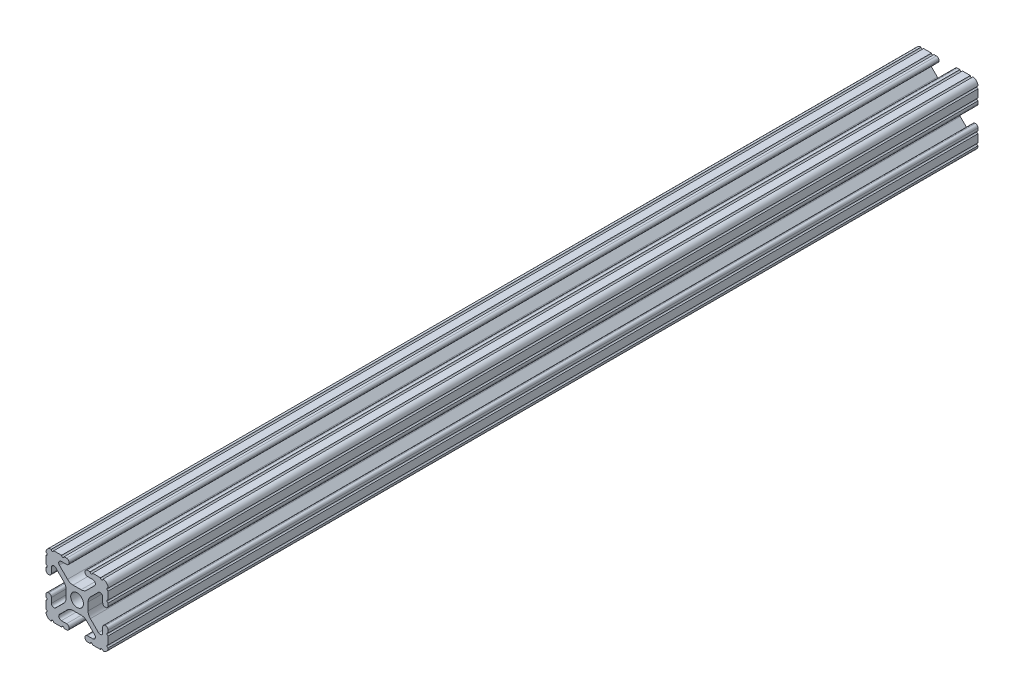
from build123d import *

# Parameters (mm, degrees)
SKETCH1_R           = 2.6035
BOSS_EXTRUDE1_DEPTH = 177.8


with BuildPart() as part:
    # Sketch1 → Boss-Extrude1 (new body, symmetric)
    with BuildSketch(Plane.XY):
        with BuildLine():
            Line((-7.179650497, -8.645192506), (-3.952270251, -5.423690499))
            ThreePointArc((-3.952270251, -5.423690499), (-2.922936451, -4.736929036), (-1.709253557, -4.4958))
            Line((-1.709253557, -4.4958), (1.709253557, -4.4958))
            ThreePointArc((1.709253557, -4.4958), (2.922936451, -4.736929036), (3.952270251, -5.423690499))
            Line((3.952270251, -5.423690499), (7.179650497, -8.645192506))
            ThreePointArc((7.179650497, -8.645192506), (7.41473083, -9.822813117), (6.416408329, -10.4902))
            Line((6.416408329, -10.4902), (4.287512407, -10.4902))
            ThreePointArc((4.287512407, -10.4902), (3.54574862, -10.79744862), (3.2385, -11.539212407))
            Line((3.2385, -11.539212407), (3.2385, -11.650987593))
            ThreePointArc((3.2385, -11.650987593), (3.54574862, -12.39275138), (4.287512407, -12.7))
            Line((4.287512407, -12.7), (5.317126718, -12.7))
            ThreePointArc((5.317126718, -12.7), (5.825126718, -12.192), (6.333126718, -12.7))
            Line((6.333126718, -12.7), (9.550443118, -12.7))
            ThreePointArc((9.550443118, -12.7), (10.058366869, -12.192000006), (10.566443095, -12.699847501))
            ThreePointArc((10.566443095, -12.699847501), (12.082537762, -12.08250727), (12.699846982, -10.566399977))
            ThreePointArc((12.699846982, -10.566399977), (12.192000006, -10.058323491), (12.7, -9.5504))
            Line((12.7, -9.5504), (12.7, -6.3330836))
            ThreePointArc((12.7, -6.3330836), (12.192, -5.8250836), (12.7, -5.3170836))
            Line((12.7, -5.3170836), (12.7, -4.287469289))
            ThreePointArc((12.7, -4.287469289), (12.39275138, -3.545705502), (11.650987593, -3.238456882))
            Line((11.650987593, -3.238456882), (11.539212407, -3.238456882))
            ThreePointArc((11.539212407, -3.238456882), (10.79744862, -3.545705502), (10.4902, -4.287469289))
            Line((10.4902, -4.287469289), (10.4902, -6.402089023))
            ThreePointArc((10.4902, -6.402089023), (9.856505071, -7.351067942), (8.737131347, -7.129408934))
            Line((8.737131347, -7.129408934), (5.441005833, -3.840816462))
            ThreePointArc((5.441005833, -3.840816462), (4.750877967, -2.809883091), (4.5085, -1.593185507))
            Line((4.5085, -1.593185507), (4.5085, 1.593185507))
            ThreePointArc((4.5085, 1.593185507), (4.750877967, 2.809883091), (5.441005833, 3.840816462))
            Line((5.441005833, 3.840816462), (8.737131347, 7.129408934))
            ThreePointArc((8.737131347, 7.129408934), (9.856505071, 7.351067942), (10.4902, 6.402089023))
            Line((10.4902, 6.402089023), (10.4902, 4.287469289))
            ThreePointArc((10.4902, 4.287469289), (10.79744862, 3.545705502), (11.539212407, 3.238456882))
            Line((11.539212407, 3.238456882), (11.650987593, 3.238456882))
            ThreePointArc((11.650987593, 3.238456882), (12.39275138, 3.545705502), (12.7, 4.287469289))
            Line((12.7, 4.287469289), (12.7, 5.3170836))
            ThreePointArc((12.7, 5.3170836), (12.192, 5.8250836), (12.7, 6.3330836))
            Line((12.7, 6.3330836), (12.7, 9.5504))
            ThreePointArc((12.7, 9.5504), (12.192000006, 10.058323491), (12.699846982, 10.566399977))
            ThreePointArc((12.699846982, 10.566399977), (12.082537762, 12.08250727), (10.566443095, 12.699847501))
            ThreePointArc((10.566443095, 12.699847501), (10.058366869, 12.192000006), (9.550443118, 12.7))
            Line((9.550443118, 12.7), (6.333126718, 12.7))
            ThreePointArc((6.333126718, 12.7), (5.825126718, 12.192), (5.317126718, 12.7))
            Line((5.317126718, 12.7), (4.287512407, 12.7))
            ThreePointArc((4.287512407, 12.7), (3.54574862, 12.39275138), (3.2385, 11.650987593))
            Line((3.2385, 11.650987593), (3.2385, 11.539212407))
            ThreePointArc((3.2385, 11.539212407), (3.54574862, 10.79744862), (4.287512407, 10.4902))
            Line((4.287512407, 10.4902), (6.476788598, 10.4902))
            ThreePointArc((6.476788598, 10.4902), (7.432222385, 9.85140422), (7.207036008, 8.724370562))
            Line((7.207036008, 8.724370562), (3.898272566, 5.423169045))
            ThreePointArc((3.898272566, 5.423169045), (2.869120213, 4.736787962), (1.655778399, 4.4958))
            Line((1.655778399, 4.4958), (-1.655778399, 4.4958))
            ThreePointArc((-1.655778399, 4.4958), (-2.869120213, 4.736787962), (-3.898272566, 5.423169045))
            Line((-3.898272566, 5.423169045), (-7.207036008, 8.724370562))
            ThreePointArc((-7.207036008, 8.724370562), (-7.432222385, 9.85140422), (-6.476788598, 10.4902))
            Line((-6.476788598, 10.4902), (-4.287512407, 10.4902))
            ThreePointArc((-4.287512407, 10.4902), (-3.54574862, 10.79744862), (-3.2385, 11.539212407))
            Line((-3.2385, 11.539212407), (-3.2385, 11.650987593))
            ThreePointArc((-3.2385, 11.650987593), (-3.54574862, 12.39275138), (-4.287512407, 12.7))
            Line((-4.287512407, 12.7), (-5.317126718, 12.7))
            ThreePointArc((-5.317126718, 12.7), (-5.825126718, 12.192), (-6.333126718, 12.7))
            Line((-6.333126718, 12.7), (-9.550443118, 12.7))
            ThreePointArc((-9.550443118, 12.7), (-10.058366869, 12.192000006), (-10.566443095, 12.699847501))
            ThreePointArc((-10.566443095, 12.699847501), (-12.082537762, 12.08250727), (-12.699846982, 10.566399977))
            ThreePointArc((-12.699846982, 10.566399977), (-12.192000006, 10.058323491), (-12.7, 9.5504))
            Line((-12.7, 9.5504), (-12.7, 6.3330836))
            ThreePointArc((-12.7, 6.3330836), (-12.192, 5.8250836), (-12.7, 5.3170836))
            Line((-12.7, 5.3170836), (-12.7, 4.287469289))
            ThreePointArc((-12.7, 4.287469289), (-12.39275138, 3.545705502), (-11.650987593, 3.238456882))
            Line((-11.650987593, 3.238456882), (-11.539212407, 3.238456882))
            ThreePointArc((-11.539212407, 3.238456882), (-10.79744862, 3.545705502), (-10.4902, 4.287469289))
            Line((-10.4902, 4.287469289), (-10.4902, 6.402089023))
            ThreePointArc((-10.4902, 6.402089023), (-9.856505071, 7.351067942), (-8.737131347, 7.129408934))
            Line((-8.737131347, 7.129408934), (-5.441005833, 3.840816462))
            ThreePointArc((-5.441005833, 3.840816462), (-4.750877967, 2.809883091), (-4.5085, 1.593185507))
            Line((-4.5085, 1.593185507), (-4.5085, -1.593185507))
            ThreePointArc((-4.5085, -1.593185507), (-4.750877967, -2.809883091), (-5.441005833, -3.840816462))
            Line((-5.441005833, -3.840816462), (-8.737131347, -7.129408934))
            ThreePointArc((-8.737131347, -7.129408934), (-9.856505071, -7.351067942), (-10.4902, -6.402089023))
            Line((-10.4902, -6.402089023), (-10.4902, -4.287469289))
            ThreePointArc((-10.4902, -4.287469289), (-10.79744862, -3.545705502), (-11.539212407, -3.238456882))
            Line((-11.539212407, -3.238456882), (-11.650987593, -3.238456882))
            ThreePointArc((-11.650987593, -3.238456882), (-12.39275138, -3.545705502), (-12.7, -4.287469289))
            Line((-12.7, -4.287469289), (-12.7, -5.3170836))
            ThreePointArc((-12.7, -5.3170836), (-12.192, -5.8250836), (-12.7, -6.3330836))
            Line((-12.7, -6.3330836), (-12.7, -9.5504))
            ThreePointArc((-12.7, -9.5504), (-12.192000006, -10.058323491), (-12.699846982, -10.566399977))
            ThreePointArc((-12.699846982, -10.566399977), (-12.082537762, -12.08250727), (-10.566443095, -12.699847501))
            ThreePointArc((-10.566443095, -12.699847501), (-10.058366869, -12.192000006), (-9.550443118, -12.7))
            Line((-9.550443118, -12.7), (-6.333126718, -12.7))
            ThreePointArc((-6.333126718, -12.7), (-5.825126718, -12.192), (-5.317126718, -12.7))
            Line((-5.317126718, -12.7), (-4.287512407, -12.7))
            ThreePointArc((-4.287512407, -12.7), (-3.54574862, -12.39275138), (-3.2385, -11.650987593))
            Line((-3.2385, -11.650987593), (-3.2385, -11.539212407))
            ThreePointArc((-3.2385, -11.539212407), (-3.54574862, -10.79744862), (-4.287512407, -10.4902))
            Line((-4.287512407, -10.4902), (-6.416408329, -10.4902))
            ThreePointArc((-6.416408329, -10.4902), (-7.41473083, -9.822813117), (-7.179650497, -8.645192506))
        make_face()
        Circle(SKETCH1_R, mode=Mode.SUBTRACT)
    extrude(amount=BOSS_EXTRUDE1_DEPTH, both=True)


solid = part.part
